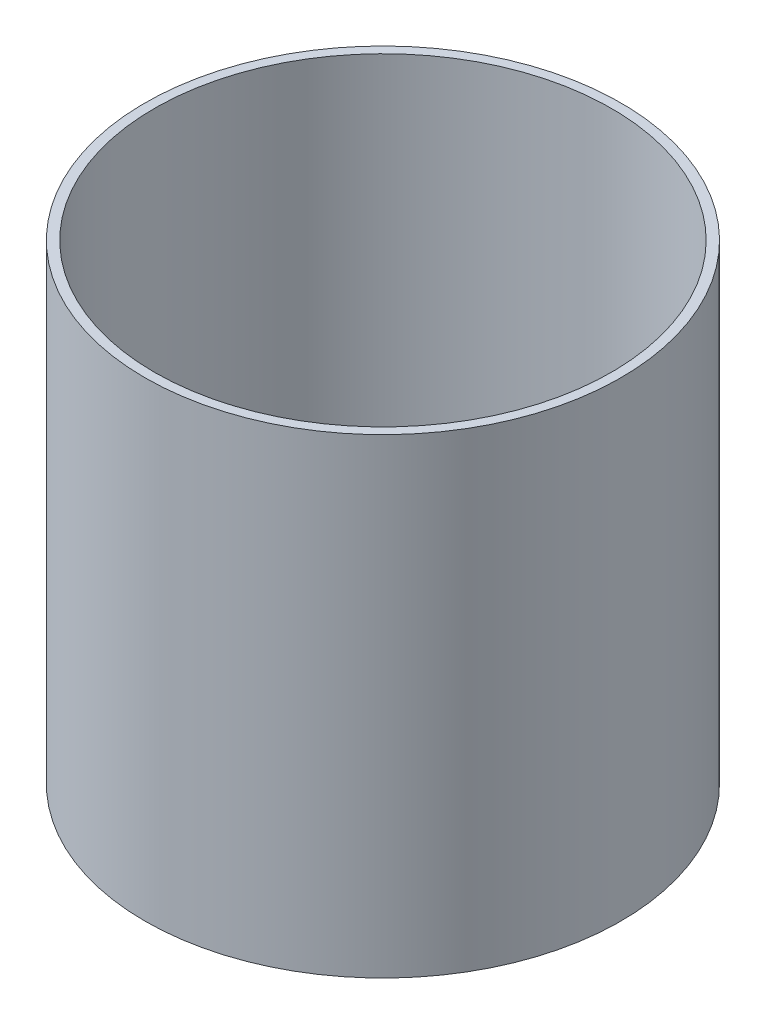
from build123d import *

# Parameters (mm, degrees)
SKETCH2_R           = 57.15
BOSS_EXTRUDE3_DEPTH = 113
SKETCH8_R           = 54.881490199
CUT_EXTRUDE1_DEPTH  = 109


with BuildPart() as part:
    # Sketch2 → Boss-Extrude3 (new body)
    with BuildSketch(Plane(origin=(0, 0, 0), x_dir=(1, 0, 0), z_dir=(0, 1, 0))):
        Circle(SKETCH2_R)
    extrude(amount=BOSS_EXTRUDE3_DEPTH)

    # Sketch8 → Cut-Extrude1 (cut)
    with BuildSketch(Plane(origin=(0, 113, 0), x_dir=(1, 0, 0), z_dir=(0, 1, 0))):
        Circle(SKETCH8_R)
    extrude(amount=-CUT_EXTRUDE1_DEPTH, mode=Mode.SUBTRACT)


solid = part.part
